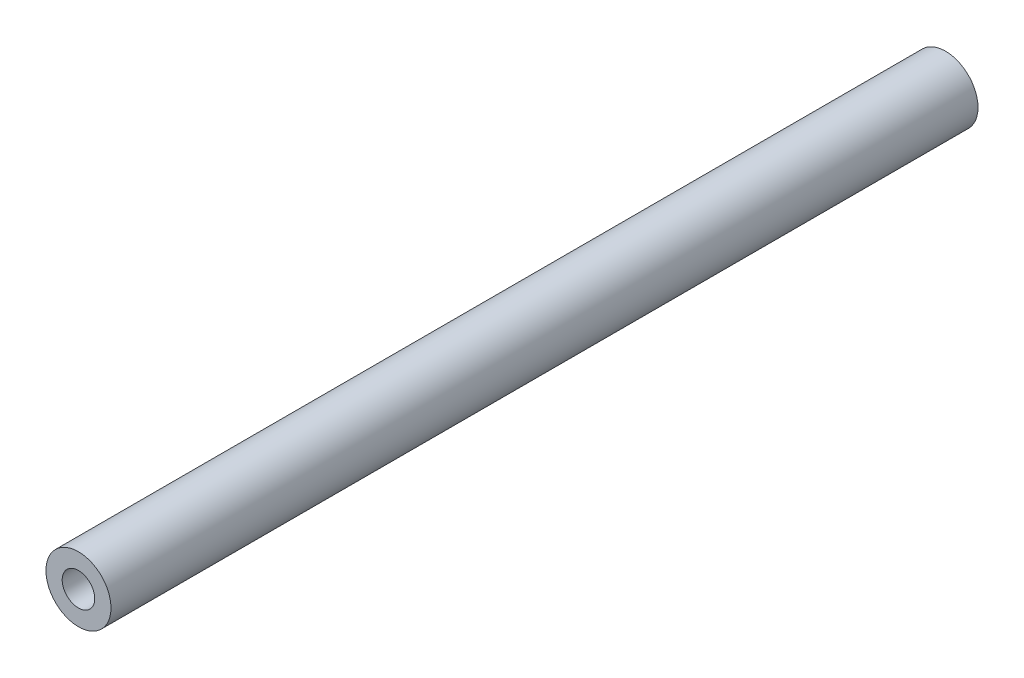
from build123d import *

# Parameters (mm, degrees)
SKETCH_1_R      = 3
SKETCH_1_R_2    = 1.5
EXTRUDE_1_DEPTH = 80


with BuildPart() as part:
    # 草图1 → 凸台-拉伸1 (new body)
    with BuildSketch(Plane.XY):
        Circle(SKETCH_1_R)
        Circle(SKETCH_1_R_2, mode=Mode.SUBTRACT)
    extrude(amount=EXTRUDE_1_DEPTH)


solid = part.part
